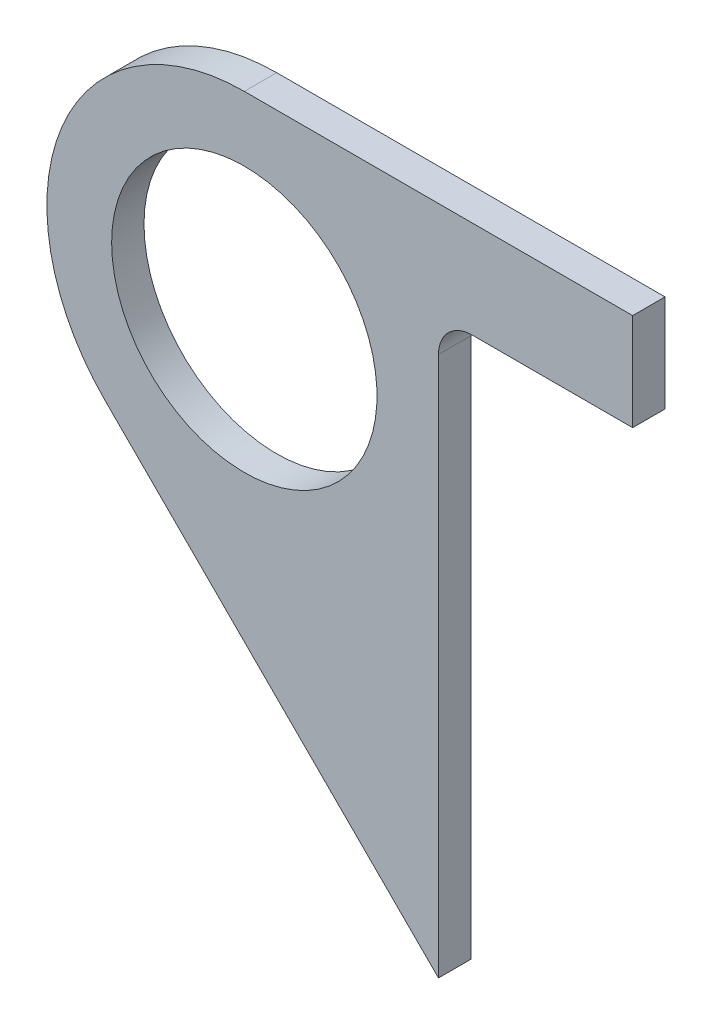
from build123d import *

# Parameters (mm, degrees)
SKETCH1_R           = 26.035
BOSS_EXTRUDE1_DEPTH = 6.35
FILLET1_R           = 6.604


with BuildPart() as part:
    # Sketch1 → Boss-Extrude1 (new body)
    with BuildSketch(Plane(origin=(0, 0, 457.2), x_dir=(-1, 0, 0), z_dir=(0, 0, -1))):
        with BuildLine():
            Line((273.05, 603.25), (273.05, 584.2))
            Line((273.05, 584.2), (311.15, 584.2))
            Line((311.15, 584.2), (311.15, 471.635437661))
            Line((311.15, 471.635437661), (376.639781169, 537.125218831))
            ThreePointArc((376.639781169, 537.125218831), (385.036473692, 579.338242753), (349.25, 603.25))
            Line((349.25, 603.25), (273.05, 603.25))
        make_face()
        with Locations((349.25, 564.515)):
            Circle(SKETCH1_R, mode=Mode.SUBTRACT)
    extrude(amount=BOSS_EXTRUDE1_DEPTH)

    # Fillet1
    fillet1_edges = [part.edges().sort_by_distance(p)[0] for p in [
        (-311.15, 584.2, 454.025),
    ]]
    fillet(fillet1_edges, radius=FILLET1_R)


solid = part.part
